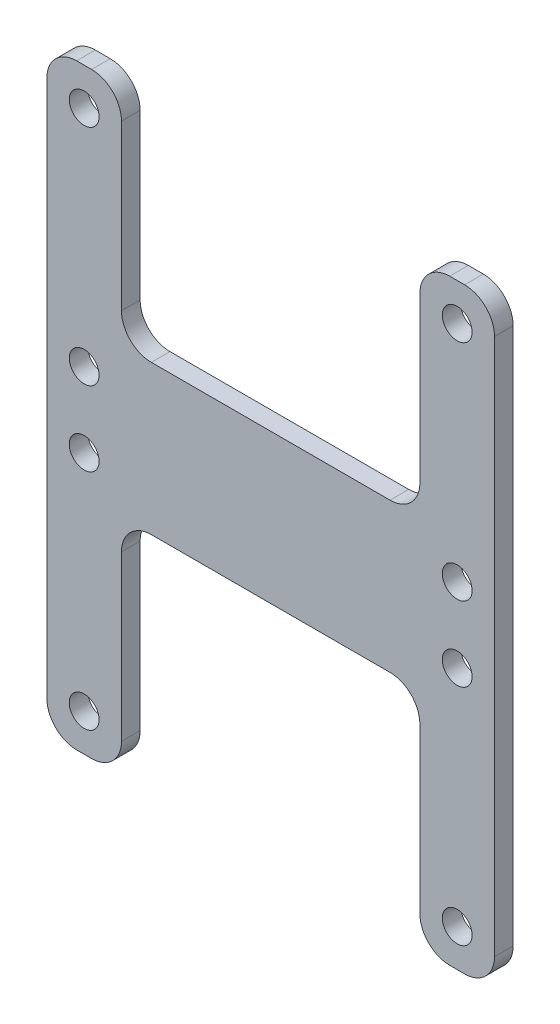
from build123d import *

# Parameters (mm, degrees)
BOSS_EXTRUDE1_DEPTH = 3.175
SKETCH4_R           = 2.54
CUT_EXTRUDE3_DEPTH  = 4.175
FILLET1_R           = 5.08
FILLET2_R           = 5.08


with BuildPart() as part:
    # Sketch1 → Boss-Extrude1 (new body)
    with BuildSketch(Plane.XY):
        Polygon((-38.1, 50.8), (-25.4, 50.8), (-25.4, 12.7), (25.4, 12.7), (25.4, 50.8), (38.1, 50.8), (38.1, -50.8), (25.4, -50.8), (25.4, -12.7), (-25.4, -12.7), (-25.4, -50.8), (-38.1, -50.8), align=None)
    extrude(amount=BOSS_EXTRUDE1_DEPTH)

    # Sketch4 → Cut-Extrude3 (cut, through all)
    with BuildSketch(Plane.XY.offset(3.175)):
        with Locations((-31.75, 44.45)):
            Circle(SKETCH4_R)
        with Locations((-31.75, 6.35)):
            Circle(SKETCH4_R)
        with Locations((31.75, 6.35)):
            Circle(SKETCH4_R)
        with Locations((31.75, 44.45)):
            Circle(SKETCH4_R)
        with Locations((-31.75, -6.35)):
            Circle(SKETCH4_R)
        with Locations((31.75, -6.35)):
            Circle(SKETCH4_R)
        with Locations((31.75, -44.45)):
            Circle(SKETCH4_R)
        with Locations((-31.75, -44.45)):
            Circle(SKETCH4_R)
    extrude(amount=-CUT_EXTRUDE3_DEPTH, mode=Mode.SUBTRACT)

    # Fillet1
    fillet1_edges = [part.edges().sort_by_distance(p)[0] for p in [
        (25.4, -12.7, 1.5875),
        (-25.4, -12.7, 1.5875),
        (-25.4, 12.7, 1.5875),
        (25.4, 12.7, 1.5875),
    ]]
    fillet(fillet1_edges, radius=FILLET1_R)

    # Fillet2
    fillet2_edges = [part.edges().sort_by_distance(p)[0] for p in [
        (38.1, 50.8, 1.5875),
        (38.1, -50.8, 1.5875),
        (25.4, -50.8, 1.5875),
        (-25.4, -50.8, 1.5875),
        (-38.1, -50.8, 1.5875),
        (-38.1, 50.8, 1.5875),
        (-25.4, 50.8, 1.5875),
        (25.4, 50.8, 1.5875),
    ]]
    fillet(fillet2_edges, radius=FILLET2_R)


solid = part.part
